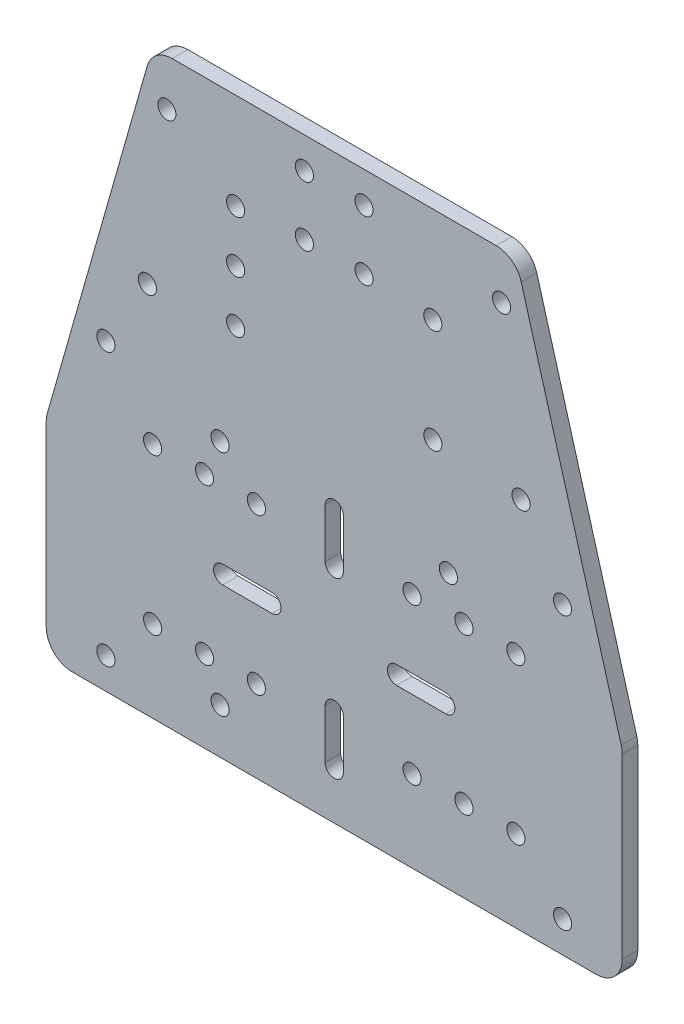
from build123d import *

# Parameters (mm, degrees)
EXTRUDE_1_DEPTH         = 3
HOLE_WIZARD_3_5_3_5_1_D = 3.5
CUT_EXTRUDE_1_DEPTH     = 91.957407615
FILLET_1_R              = 5


with BuildPart() as part:
    # 草图1 → 凸台-拉伸1 (new body)
    with BuildSketch(Plane.XY):
        Polygon((-55.5, 0), (-55.5, -40), (55.5, -40), (55.5, 0), (35, 72), (-35, 72), align=None)
    extrude(amount=EXTRUDE_1_DEPTH)

    # Ø3.5 (3.5) 直径孔1 (through all)
    with Locations(Plane.XY.offset(3)):
        with Locations((-5.75, 54.5), (5.75, 54.5), (5.75, 66), (-5.75, 66), (-32.25, 63), (-36, 32), (36, 32), (32.25, 63), (-44, 18.5), (44, 18.5), (44, -34), (-44, -34), (-22, -31.25), (-15, -24.25), (15, -24.25), (15, 5.75), (-15, 5.75), (-22, 12.75), (22, 12.75), (-19, 53.5), (-19, 43.5), (-19, 33.5), (19, 33.5), (19, 53.5), (-25, 5.75), (-25, -24.25), (-35, 5.75), (-35, -24.25), (25, 5.75), (35, 5.75), (35, -24.25), (25, -24.25)):
            Hole(HOLE_WIZARD_3_5_3_5_1_D / 2)

    # 草图2 → 切除-拉伸1 (cut, through all)
    with BuildSketch(Plane.XY.offset(3)):
        with BuildLine():
            Line((1.75, -21.25), (1.75, -30.75))
            ThreePointArc((1.75, -30.75), (0, -32.5), (-1.75, -30.75))
            Line((-1.75, -30.75), (-1.75, -21.25))
            ThreePointArc((-1.75, -21.25), (0, -19.5), (1.75, -21.25))
        make_face()
        with BuildLine():
            Line((12, -7.5), (21.5, -7.5))
            ThreePointArc((21.5, -7.5), (23.25, -9.25), (21.5, -11))
            Line((21.5, -11), (12, -11))
            ThreePointArc((12, -11), (10.25, -9.25), (12, -7.5))
        make_face()
        with BuildLine():
            Line((1.75, 2.75), (1.75, 12.25))
            ThreePointArc((1.75, 12.25), (0, 14), (-1.75, 12.25))
            Line((-1.75, 12.25), (-1.75, 2.75))
            ThreePointArc((-1.75, 2.75), (0, 1), (1.75, 2.75))
        make_face()
        with BuildLine():
            Line((-12, -7.5), (-21.5, -7.5))
            ThreePointArc((-21.5, -7.5), (-23.25, -9.25), (-21.5, -11))
            Line((-21.5, -11), (-12, -11))
            ThreePointArc((-12, -11), (-10.25, -9.25), (-12, -7.5))
        make_face()
    extrude(amount=-CUT_EXTRUDE_1_DEPTH, mode=Mode.SUBTRACT)

    # 圆角1
    fillet_1_edges = [part.edges().sort_by_distance(p)[0] for p in [
        (-55.5, 0, 1.5),
        (-55.5, -40, 1.5),
        (55.5, -40, 1.5),
        (55.5, 0, 1.5),
        (35, 72, 1.5),
        (-35, 72, 1.5),
    ]]
    fillet(fillet_1_edges, radius=FILLET_1_R)


solid = part.part
